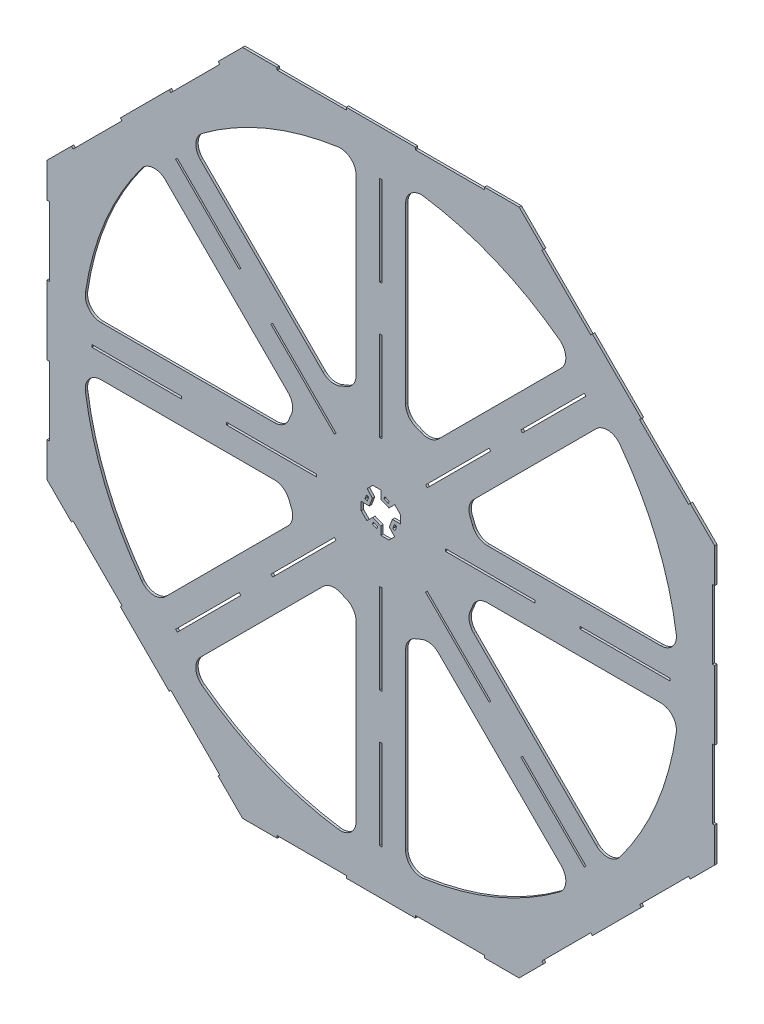
from build123d import *

# Parameters (mm, degrees)
ESBO_O1_W                  = 3
ESBO_O1_H                  = 114.285714286
ESBO_O1_W_2                = 114.285714286
ESBO_O1_H_2                = 3
RESSALTO_EXTRUS_O1_DEPTH   = 3
CORTE_EXTRUS_O1_DEPTH      = 1
CORTE_EXTRUS_O1_DEPTH_BACK = 4
FILETE1_R                  = 20


with BuildPart() as part:
    # Esboço1 → Ressalto-extrusão1 (new body)
    with BuildSketch(Plane.XY):
        Polygon((-176.040764009, -425), (-132.030573006, -425), (-132.030573006, -422), (-44.010191001, -422), (-44.010191001, -425), (44.010191004, -425), (44.010191004, -422), (132.030573009, -422), (132.030573009, -425), (176.040764009, -425), (207.160668508, -393.880095501), (205.039348164, -391.758775157), (267.279157163, -329.518966159), (269.400477506, -331.640286502), (331.640286504, -269.400477504), (329.518966161, -267.279157161), (391.758775159, -205.039348162), (393.880095503, -207.160668506), (425, -176.040764009), (425, -132.030573006), (422, -132.030573006), (422, -44.010191001), (425, -44.010191001), (425, 44.010191004), (422, 44.010191004), (422, 132.030573009), (425, 132.030573009), (425, 176.040764009), (393.880095501, 207.160668508), (391.758775157, 205.039348164), (329.518966159, 267.279157163), (331.640286502, 269.400477506), (269.400477504, 331.640286504), (267.279157161, 329.518966161), (205.039348162, 391.758775159), (207.160668506, 393.880095503), (176.040764009, 425), (132.030573006, 425), (132.030573006, 422), (44.010191001, 422), (44.010191001, 425), (-44.010191004, 425), (-44.010191004, 422), (-132.030573009, 422), (-132.030573009, 425), (-176.040764009, 425), (-207.160668508, 393.880095501), (-205.039348164, 391.758775157), (-267.279157163, 329.518966159), (-269.400477506, 331.640286502), (-331.640286504, 269.400477504), (-329.518966161, 267.279157161), (-391.758775159, 205.039348162), (-393.880095503, 207.160668506), (-425, 176.040764009), (-425, 132.030573006), (-422, 132.030573006), (-422, 44.010191001), (-425, 44.010191001), (-425, -44.010191004), (-422, -44.010191004), (-422, -132.030573009), (-425, -132.030573009), (-425, -176.040764009), (-393.880095501, -207.160668508), (-391.758775157, -205.039348164), (-329.518966159, -267.279157163), (-331.640286502, -269.400477506), (-269.400477504, -331.640286504), (-267.279157161, -329.518966161), (-205.039348162, -391.758775159), (-207.160668506, -393.880095503), align=None)
        Polygon((-10.355339059, 25), (0, 25), (0, 14.644660941), (10.355339059, 10.355339059), (17.67766953, 17.67766953), (25, 10.355339059), (25, 0), (14.644660941, 0), (10.744098627, -10.516368545), (17.67766953, -17.67766953), (10.355339059, -25), (0, -25), (0, -14.644660941), (-10.355339059, -10.355339059), (-17.67766953, -17.67766953), (-25, -10.355339059), (-25, 0), (-14.644660941, 0), (-10.744098627, 10.516368545), (-17.412937055, 17.942402005), align=None, mode=Mode.SUBTRACT)
        Polygon((180.36273683, -178.241416486), (261.174940394, -259.05362005), (259.05362005, -261.174940394), (178.241416486, -180.36273683), align=None, mode=Mode.SUBTRACT)
        Polygon((59.144431484, -57.02311114), (139.956635048, -137.835314704), (137.835314704, -139.956635048), (57.02311114, -59.144431484), align=None, mode=Mode.SUBTRACT)
        with Locations((0, -310.714285714)):
            Rectangle(ESBO_O1_W, ESBO_O1_H, mode=Mode.SUBTRACT)
        Polygon((-9.480041857, -15.047467833), (-3.936764662, -17.343568427), (-5.084814959, -20.115207025), (-10.628092154, -17.81910643), align=None, mode=Mode.SUBTRACT)
        with Locations((0, -139.285714286)):
            Rectangle(ESBO_O1_W, ESBO_O1_H, mode=Mode.SUBTRACT)
        Polygon((-17.396597781, 4.082835514), (-20.209354971, 5.12609818), (-18.122829637, 10.75161256), (-15.310072448, 9.708349893), align=None, mode=Mode.SUBTRACT)
        Polygon((3.936764662, 17.343568427), (5.084814959, 20.115207025), (10.628092154, 17.81910643), (9.480041857, 15.047467833), align=None, mode=Mode.SUBTRACT)
        Polygon((17.396597781, -4.082835514), (20.209354971, -5.12609818), (18.122829637, -10.75161256), (15.310072448, -9.708349893), align=None, mode=Mode.SUBTRACT)
        with Locations((310.714285714, 0)):
            Rectangle(ESBO_O1_W_2, ESBO_O1_H_2, mode=Mode.SUBTRACT)
        with Locations((139.285714286, 0)):
            Rectangle(ESBO_O1_W_2, ESBO_O1_H_2, mode=Mode.SUBTRACT)
        Polygon((-178.241416486, -180.36273683), (-259.05362005, -261.174940394), (-261.174940394, -259.05362005), (-180.36273683, -178.241416486), align=None, mode=Mode.SUBTRACT)
        Polygon((-57.02311114, -59.144431484), (-137.835314704, -139.956635048), (-139.956635048, -137.835314704), (-59.144431484, -57.02311114), align=None, mode=Mode.SUBTRACT)
        with Locations((-310.714285714, 0)):
            Rectangle(ESBO_O1_W_2, ESBO_O1_H_2, mode=Mode.SUBTRACT)
        with Locations((-139.285714286, 0)):
            Rectangle(ESBO_O1_W_2, ESBO_O1_H_2, mode=Mode.SUBTRACT)
        Polygon((-180.36273683, 178.241416486), (-261.174940394, 259.05362005), (-259.05362005, 261.174940394), (-178.241416486, 180.36273683), align=None, mode=Mode.SUBTRACT)
        Polygon((-59.144431484, 57.02311114), (-139.956635048, 137.835314704), (-137.835314704, 139.956635048), (-57.02311114, 59.144431484), align=None, mode=Mode.SUBTRACT)
        with Locations((0, 310.714285714)):
            Rectangle(ESBO_O1_W, ESBO_O1_H, mode=Mode.SUBTRACT)
        with Locations((0, 139.285714286)):
            Rectangle(ESBO_O1_W, ESBO_O1_H, mode=Mode.SUBTRACT)
        Polygon((178.241416486, 180.36273683), (259.05362005, 261.174940394), (261.174940394, 259.05362005), (180.36273683, 178.241416486), align=None, mode=Mode.SUBTRACT)
        Polygon((57.02311114, 59.144431484), (137.835314704, 139.956635048), (139.956635048, 137.835314704), (59.144431484, 57.02311114), align=None, mode=Mode.SUBTRACT)
    extrude(amount=RESSALTO_EXTRUS_O1_DEPTH)

    # Esboço2 → Corte-extrusão1 (cut, two sides)
    with BuildSketch(Plane(origin=(0, 0, 0), x_dir=(-1, 0, 0), z_dir=(0, 0, -1))) as corte_extrus_o1_sk:
        with BuildLine():
            ThreePointArc((-63.261947606, 107.809674821), (-47.835429046, 115.484941564), (-31.5, 120.965904287))
            Line((-31.5, 120.965904287), (-31.5, 378.692157299))
            ThreePointArc((-31.5, 378.692157299), (-145.419704299, 351.074222354), (-245.501928801, 290.049656016))
            Line((-245.501928801, 290.049656016), (-63.261947606, 107.809674821))
        make_face()
        with BuildLine():
            Line((31.5, 378.692157299), (31.5, 120.965904287))
            ThreePointArc((31.5, 120.965904287), (47.835429046, 115.484941564), (63.261947606, 107.809674821))
            Line((63.261947606, 107.809674821), (245.501928801, 290.049656016))
            ThreePointArc((245.501928801, 290.049656016), (145.419704299, 351.074222354), (31.5, 378.692157299))
        make_face()
        with BuildLine():
            Line((290.049656016, 245.501928801), (107.809674821, 63.261947606))
            ThreePointArc((107.809674821, 63.261947606), (115.484941564, 47.835429046), (120.965904287, 31.5))
            Line((120.965904287, 31.5), (378.692157299, 31.5))
            ThreePointArc((378.692157299, 31.5), (351.074222354, 145.419704299), (290.049656016, 245.501928801))
        make_face()
        with BuildLine():
            Line((378.692157299, -31.5), (120.965904287, -31.5))
            ThreePointArc((120.965904287, -31.5), (115.484941564, -47.835429046), (107.809674821, -63.261947606))
            Line((107.809674821, -63.261947606), (290.049656016, -245.501928801))
            ThreePointArc((290.049656016, -245.501928801), (351.074222354, -145.419704299), (378.692157299, -31.5))
        make_face()
        with BuildLine():
            Line((245.501928801, -290.049656016), (63.261947606, -107.809674821))
            ThreePointArc((63.261947606, -107.809674821), (47.835429046, -115.484941564), (31.5, -120.965904287))
            Line((31.5, -120.965904287), (31.5, -378.692157299))
            ThreePointArc((31.5, -378.692157299), (145.419704299, -351.074222354), (245.501928801, -290.049656016))
        make_face()
        with BuildLine():
            ThreePointArc((-31.5, -120.965904287), (-47.835429046, -115.484941564), (-63.261947606, -107.809674821))
            Line((-63.261947606, -107.809674821), (-245.501928801, -290.049656016))
            ThreePointArc((-245.501928801, -290.049656016), (-145.419704299, -351.074222354), (-31.5, -378.692157299))
            Line((-31.5, -378.692157299), (-31.5, -120.965904287))
        make_face()
        with BuildLine():
            ThreePointArc((-107.809674821, -63.261947606), (-115.484941564, -47.835429046), (-120.965904287, -31.5))
            Line((-120.965904287, -31.5), (-378.692157299, -31.5))
            ThreePointArc((-378.692157299, -31.5), (-351.074222354, -145.419704299), (-290.049656016, -245.501928801))
            Line((-290.049656016, -245.501928801), (-107.809674821, -63.261947606))
        make_face()
        with BuildLine():
            ThreePointArc((-120.965904287, 31.5), (-115.484941564, 47.835429046), (-107.809674821, 63.261947606))
            Line((-107.809674821, 63.261947606), (-290.049656016, 245.501928801))
            ThreePointArc((-290.049656016, 245.501928801), (-351.074222354, 145.419704299), (-378.692157299, 31.5))
            Line((-378.692157299, 31.5), (-120.965904287, 31.5))
        make_face()
    extrude(amount=CORTE_EXTRUS_O1_DEPTH, mode=Mode.SUBTRACT)
    extrude(corte_extrus_o1_sk.sketch, amount=-CORTE_EXTRUS_O1_DEPTH_BACK, mode=Mode.SUBTRACT)

    # Filete1
    filete1_edges = [part.edges().sort_by_distance(p)[0] for p in [
        (31.5, 120.965904287, 1.5),
        (63.261947606, 107.809674821, 1.5),
        (245.501928801, 290.049656016, 1.5),
        (31.5, 378.692157299, 1.5),
        (-31.5, -120.965904287, 1.5),
        (-63.261947606, -107.809674821, 1.5),
        (-245.501928801, -290.049656016, 1.5),
        (-31.5, -378.692157299, 1.5),
        (63.261947606, -107.809674821, 1.5),
        (31.5, -120.965904287, 1.5),
        (31.5, -378.692157299, 1.5),
        (245.501928801, -290.049656016, 1.5),
        (120.965904287, -31.5, 1.5),
        (107.809674821, -63.261947606, 1.5),
        (290.049656016, -245.501928801, 1.5),
        (378.692157299, -31.5, 1.5),
        (107.809674821, 63.261947606, 1.5),
        (120.965904287, 31.5, 1.5),
        (378.692157299, 31.5, 1.5),
        (290.049656016, 245.501928801, 1.5),
        (-63.261947606, 107.809674821, 1.5),
        (-31.5, 120.965904287, 1.5),
        (-31.5, 378.692157299, 1.5),
        (-245.501928801, 290.049656016, 1.5),
        (-120.965904287, 31.5, 1.5),
        (-107.809674821, 63.261947606, 1.5),
        (-290.049656016, 245.501928801, 1.5),
        (-378.692157299, 31.5, 1.5),
        (-107.809674821, -63.261947606, 1.5),
        (-120.965904287, -31.5, 1.5),
        (-378.692157299, -31.5, 1.5),
        (-290.049656016, -245.501928801, 1.5),
    ]]
    fillet(filete1_edges, radius=FILETE1_R)


solid = part.part
